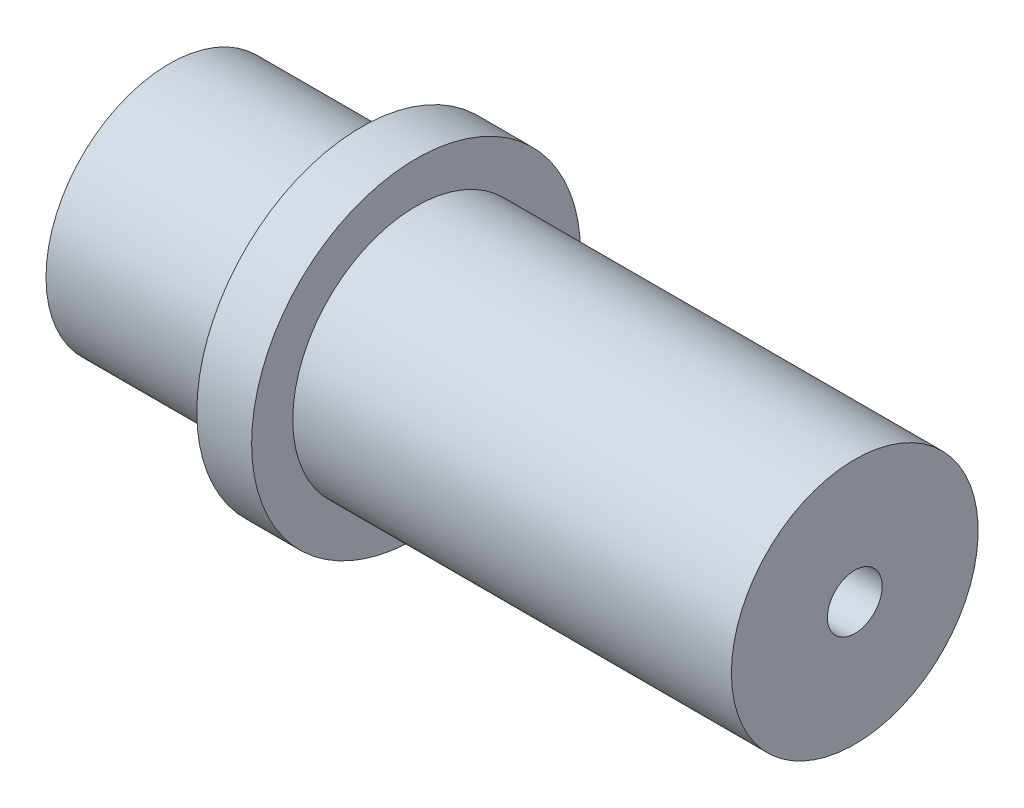
from build123d import *


with BuildPart() as part:
    # Sketch1 → Revolve1 (revolve)
    with BuildSketch(Plane.XY):
        Polygon((0, 1.875), (0, 5.625), (8.75, 5.625), (8.75, 7.5), (11.25, 7.5), (11.25, 5.625), (31.25, 5.625), (31.25, 1.25), (21.75, 1.25), (21.75, 1.875), align=None)
    revolve(axis=Axis((0, 0, 0), (1, 0, 0)))


solid = part.part
